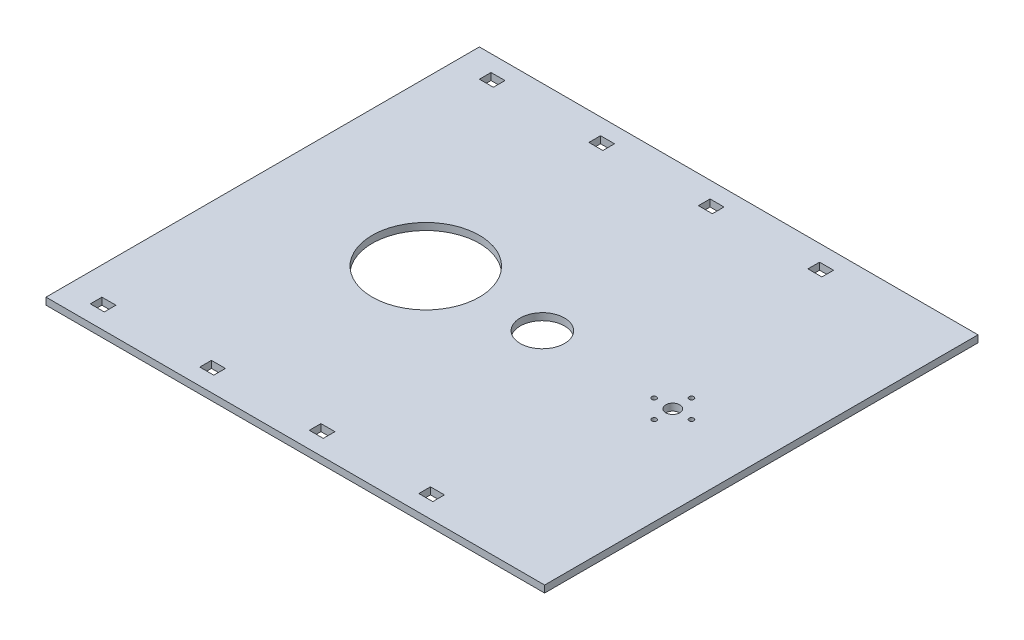
from build123d import *

# Parameters (mm, degrees)
SKETCH1_W           = 214
SKETCH1_H           = 186
BOSS_EXTRUDE1_DEPTH = 3
SKETCH2_R           = 23
SPEAKER_DEPTH       = 4
SKETCH4_R           = 3
SKETCH4_R_2         = 1.025
MOTOR_DEPTH         = 4
SKETCH6_W           = 6
SKETCH6_H           = 5
IZGARALAR_DEPTH     = 4
SKETCH7_R           = 9.5
MOTOR_KABLOSU_DEPTH = 4


with BuildPart() as part:
    # Sketch1 → Boss-Extrude1 (new body)
    with BuildSketch(Plane(origin=(0, 0, 0), x_dir=(1, 0, 0), z_dir=(0, 1, 0))):
        with Locations((-5.589552239, -39.100746269)):
            Rectangle(SKETCH1_W, SKETCH1_H)
    extrude(amount=BOSS_EXTRUDE1_DEPTH)

    # Sketch2 → Speaker (cut, through all)
    with BuildSketch(Plane(origin=(0, 3, 0), x_dir=(1, 0, 0), z_dir=(0, 1, 0))):
        with Locations((-42.589552239, -39.100746269)):
            Circle(SKETCH2_R)
    extrude(amount=-SPEAKER_DEPTH, mode=Mode.SUBTRACT)

    # Sketch4 → Motor (cut, through all)
    with BuildSketch(Plane(origin=(0, 3, 0), x_dir=(1, 0, 0), z_dir=(0, 1, 0))):
        with Locations((63.410447761, -39.100746269)):
            Circle(SKETCH4_R)
        with Locations((63.410447761, -31.100746269)):
            Circle(SKETCH4_R_2)
        with Locations((71.410447761, -39.100746269)):
            Circle(SKETCH4_R_2)
        with Locations((63.410447761, -47.100746269)):
            Circle(SKETCH4_R_2)
        with Locations((55.410447761, -39.100746269)):
            Circle(SKETCH4_R_2)
    extrude(amount=-MOTOR_DEPTH, mode=Mode.SUBTRACT)

    # Sketch6 → Izgaralar (cut, through all)
    with BuildSketch(Plane(origin=(0, 3, 0), x_dir=(1, 0, 0), z_dir=(0, 1, 0))):
        with Locations((-97.589552239, -122.600746269)):
            Rectangle(SKETCH6_W, SKETCH6_H)
        with Locations((-50.589552239, -122.600746269)):
            Rectangle(SKETCH6_W, SKETCH6_H)
        with Locations((-3.589552239, -122.600746269)):
            Rectangle(SKETCH6_W, SKETCH6_H)
        with Locations((-97.589552239, 44.399253731)):
            Rectangle(SKETCH6_W, SKETCH6_H)
        with Locations((-50.589552239, 44.399253731)):
            Rectangle(SKETCH6_W, SKETCH6_H)
        with Locations((-3.589552239, 44.399253731)):
            Rectangle(SKETCH6_W, SKETCH6_H)
        with Locations((43.410447761, -122.600746269)):
            Rectangle(SKETCH6_W, SKETCH6_H)
        with Locations((43.410447761, 44.399253731)):
            Rectangle(SKETCH6_W, SKETCH6_H)
    extrude(amount=-IZGARALAR_DEPTH, mode=Mode.SUBTRACT)

    # Sketch7 → Motor Kablosu (cut, through all)
    with BuildSketch(Plane(origin=(0, 3, 0), x_dir=(1, 0, 0), z_dir=(0, 1, 0))):
        with Locations((6.410447761, -38.065571016)):
            Circle(SKETCH7_R)
    extrude(amount=-MOTOR_KABLOSU_DEPTH, mode=Mode.SUBTRACT)


solid = part.part
